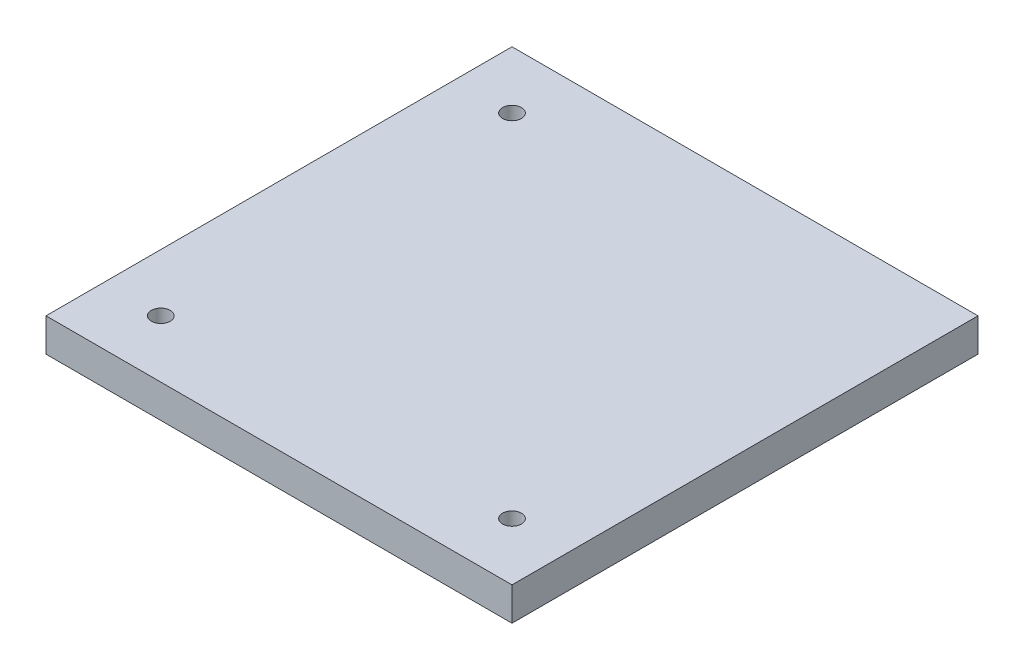
from build123d import *

# Parameters (mm, degrees)
SKETCH1_W           = 70.104
SKETCH1_H           = 70.104
BOSS_EXTRUDE1_DEPTH = 5
SKETCH2_R           = 1.4224
CUT_EXTRUDE1_DEPTH  = 6.35


with BuildPart() as part:
    # Sketch1 → Boss-Extrude1 (new body)
    with BuildSketch(Plane(origin=(0, 0, 0), x_dir=(1, 0, 0), z_dir=(0, 1, 0))):
        with Locations((35.052, 35.052)):
            Rectangle(SKETCH1_W, SKETCH1_H)
    extrude(amount=BOSS_EXTRUDE1_DEPTH)

    # Sketch2 → Cut-Extrude1 (cut)
    with BuildSketch(Plane(origin=(0, 5, 0), x_dir=(1, 0, 0), z_dir=(0, 1, 0))):
        with Locations((8.636, 8.636)):
            Circle(SKETCH2_R)
        with Locations((8.636, 61.468)):
            Circle(SKETCH2_R)
        with Locations((61.468, 8.636)):
            Circle(SKETCH2_R)
    extrude(amount=-CUT_EXTRUDE1_DEPTH, mode=Mode.SUBTRACT)


solid = part.part
